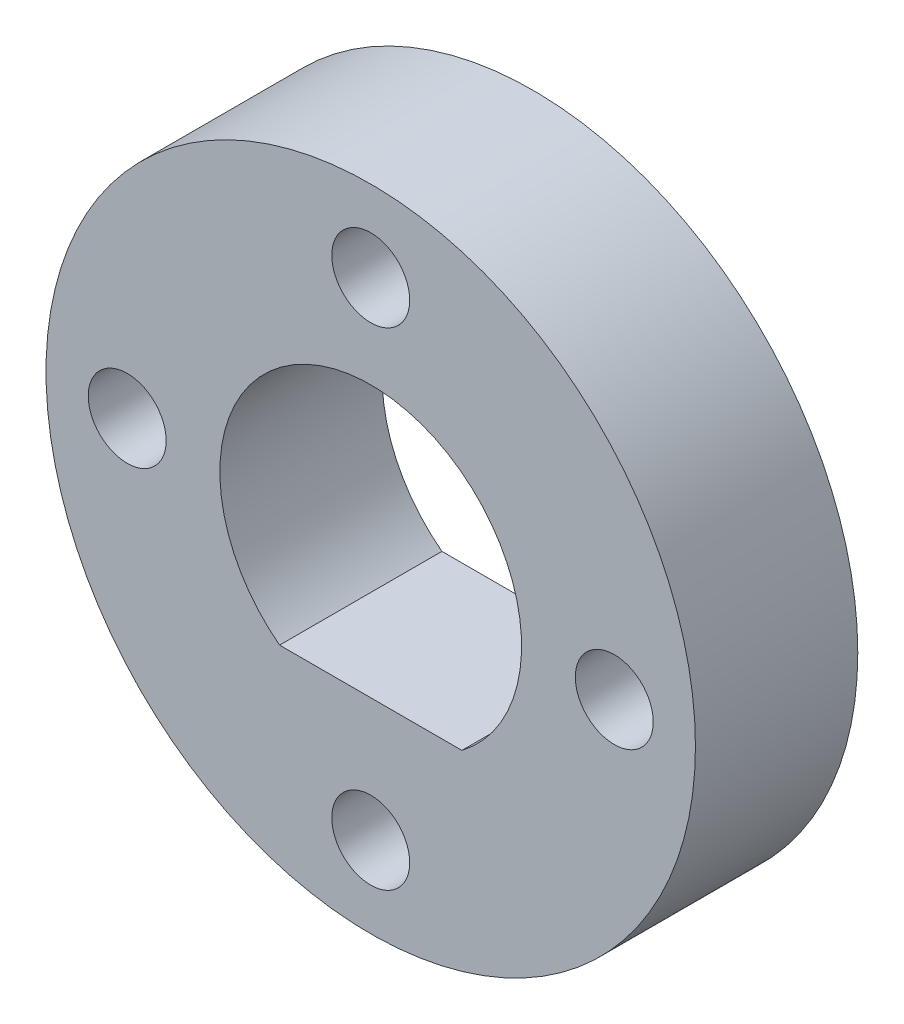
from build123d import *

# Parameters (mm, degrees)
SKETCH1_R           = 6.35
SKETCH1_R_2         = 0.762
BOSS_EXTRUDE1_DEPTH = 3.175


with BuildPart() as part:
    # Sketch1 → Boss-Extrude1 (new body)
    with BuildSketch(Plane.XY):
        Circle(SKETCH1_R)
        with Locations((0, 4.7625)):
            Circle(SKETCH1_R_2, mode=Mode.SUBTRACT)
        with Locations((4.7625, 0)):
            Circle(SKETCH1_R_2, mode=Mode.SUBTRACT)
        with Locations((0, -4.7625)):
            Circle(SKETCH1_R_2, mode=Mode.SUBTRACT)
        with Locations((-4.7625, 0)):
            Circle(SKETCH1_R_2, mode=Mode.SUBTRACT)
        with BuildLine():
            Line((-1.782587852, -2.35077), (1.782587852, -2.35077))
            ThreePointArc((1.782587852, -2.35077), (0, 2.95021), (-1.782587852, -2.35077))
        make_face(mode=Mode.SUBTRACT)
    extrude(amount=BOSS_EXTRUDE1_DEPTH)


solid = part.part
